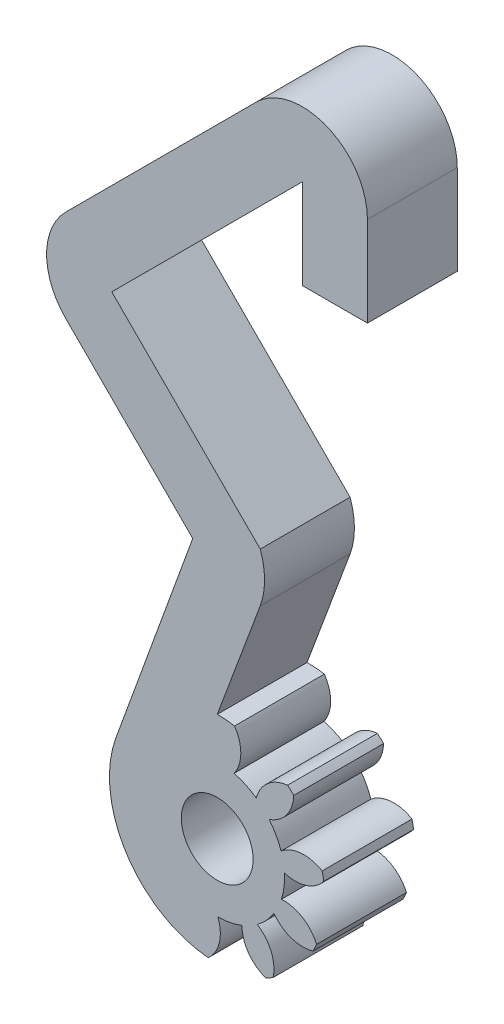
from build123d import *

# Parameters (mm, degrees)
BOSS_EXTRUDE1_DEPTH = 5
CUT_EXTRUDE1_REACH  = 47.822
SKETCH1_4_R         = 2
CUT_EXTRUDE2_DEPTH  = 5
BOSS_EXTRUDE2_DEPTH = 5
SKETCH6_R           = 2
CUT_EXTRUDE3_DEPTH  = 5


with BuildPart() as part:
    # Sketch1 → Boss-Extrude1 (new body)
    with BuildSketch(Plane.XY):
        with BuildLine():
            Line((-2.520114714, 12.269831909), (-0.124248164, 18.700029955))
            ThreePointArc((-0.124248164, 18.700029955), (0.116981353, 20.068110528), (-0.124248164, 21.436191102))
            Line((-0.124248164, 21.436191102), (-8.39066093, 29.702603869))
            Line((-8.39066093, 29.702603869), (2.215940787, 40.309205586))
            Line((2.215940787, 40.309205586), (2.215940787, 35.309205586))
            Line((2.215940787, 35.309205586), (5.841171936, 35.309205586))
            Line((5.841171936, 35.309205586), (5.841171936, 40.309205586))
            ThreePointArc((5.841171936, 40.309205586), (3.603256686, 43.658482445), (-0.347484741, 42.872631115))
            Line((-0.347484741, 42.872631115), (-10.954086459, 32.266029397))
            ThreePointArc((-10.954086459, 32.266029397), (-12.015892078, 29.702603869), (-10.954086459, 27.13917834))
            Line((-10.954086459, 27.13917834), (-3.883018647, 20.068110528))
            Line((-3.883018647, 20.068110528), (-8.158270438, 8.321952769))
            ThreePointArc((-8.158270438, 8.321952769), (0.921343905, 1.354919643), (-2.520114714, 12.269831909))
        make_face()
    extrude(amount=BOSS_EXTRUDE1_DEPTH)

    # Sketch1_4 → Cut-Extrude1 (cut, up to next)
    with BuildSketch(Plane.XY, mode=Mode.PRIVATE) as cut_extrude1_sk1:
        with Locations((-2.520114714, 6.269831909)):
            Circle(SKETCH1_4_R)
    cut_extrude1_tool1 = extrude(cut_extrude1_sk1.sketch, amount=CUT_EXTRUDE1_REACH, mode=Mode.PRIVATE) & part.part
    add(cut_extrude1_tool1.solids().sort_by_distance((-2.520115, 6.269832, 0))[0], mode=Mode.SUBTRACT)

    # Sketch5 → Cut-Extrude2 (cut)
    with BuildSketch(Plane(origin=(0, 0, 0), x_dir=(-1, 0, 0), z_dir=(0, 0, -1))):
        with BuildLine():
            Line((2.022476226, 12.24915929), (2.209173599, 10.005914968))
            ThreePointArc((2.209173599, 10.005914968), (-1.215968345, 5.958890794), (2.831055828, 2.53374885))
            Line((2.831055828, 2.53374885), (3.017753201, 0.290504527))
            ThreePointArc((3.017753201, 0.290504527), (-3.459212668, 5.772193421), (2.022476226, 12.24915929))
        make_face()
    extrude(amount=-CUT_EXTRUDE2_DEPTH, mode=Mode.SUBTRACT)

    # Sketch3 → Boss-Extrude2 (add)
    with BuildSketch(Plane.XY):
        with BuildLine():
            ThreePointArc((3.320342305, 7.644263358), (2.148599503, 7.913084677), (1.034423028, 7.461579551))
            ThreePointArc((1.034423028, 7.461579551), (0.758834569, 8.087383175), (0.37416263, 8.65272084))
            ThreePointArc((0.37416263, 8.65272084), (1.347484271, 9.358334814), (1.740439947, 10.494482662))
            ThreePointArc((1.740439947, 10.494482662), (1.571875447, 10.657954118), (1.397043733, 10.814704811))
            ThreePointArc((1.397043733, 10.814704811), (0.291074687, 10.343452688), (-0.344924962, 9.323280867))
            ThreePointArc((-0.344924962, 9.323280867), (-0.93571885, 9.667579802), (-1.579222127, 9.898843088))
            ThreePointArc((-1.579222127, 9.898843088), (-1.206537867, 11.041800891), (-1.556440997, 12.191937359))
            ThreePointArc((-1.556440997, 12.191937359), (-1.788898653, 12.225108819), (-2.022476226, 12.24915929))
            ThreePointArc((-2.022476226, 12.24915929), (-2.640228932, 11.217836019), (-2.555121505, 10.018668465))
            ThreePointArc((-2.555121505, 10.018668465), (-3.235457637, 9.949952219), (-3.891995873, 9.758806412))
            ThreePointArc((-3.891995873, 9.758806412), (-4.262301713, 10.90253701), (-5.221412546, 11.627349059))
            ThreePointArc((-5.221412546, 11.627349059), (-5.428972435, 11.517550152), (-5.632077174, 11.399713939))
            ThreePointArc((-5.632077174, 11.399713939), (-5.525653002, 10.202249956), (-4.751946644, 9.282127916))
            ThreePointArc((-4.751946644, 9.282127916), (-5.261959741, 8.826643761), (-5.680757645, 8.286100061))
            ThreePointArc((-5.680757645, 8.286100061), (-6.65260934, 8.99373724), (-7.854580137, 9.016371303))
            ThreePointArc((-7.854580137, 9.016371303), (-7.957961436, 8.805541479), (-8.053014233, 8.590828011))
            ThreePointArc((-8.053014233, 8.590828011), (-7.2630636, 7.684613857), (-6.096287842, 7.394992676))
            ThreePointArc((-6.096287842, 7.394992676), (-6.241170236, 6.726720077), (-6.262261243, 6.043247807))
            ThreePointArc((-6.262261243, 6.043247807), (-7.464444479, 6.044498216), (-8.450163248, 5.35630885))
            ThreePointArc((-8.450163248, 5.35630885), (-8.409877814, 5.124977936), (-8.360571733, 4.895400459))
            ThreePointArc((-8.360571733, 4.895400459), (-7.18882893, 4.62657914), (-6.074652455, 5.078084267))
            ThreePointArc((-6.074652455, 5.078084267), (-5.799063996, 4.452280642), (-5.414392057, 3.886942978))
            ThreePointArc((-5.414392057, 3.886942978), (-6.387713698, 3.181329004), (-6.780669374, 2.045181156))
            ThreePointArc((-6.780669374, 2.045181156), (-6.612104874, 1.881709699), (-6.43727316, 1.724959006))
            ThreePointArc((-6.43727316, 1.724959006), (-5.331304114, 2.196211129), (-4.695304465, 3.21638295))
            ThreePointArc((-4.695304465, 3.21638295), (-4.104510577, 2.872084015), (-3.4610073, 2.640820729))
            ThreePointArc((-3.4610073, 2.640820729), (-3.83369156, 1.497862927), (-3.48378843, 0.347726458))
            ThreePointArc((-3.48378843, 0.347726458), (-3.251330774, 0.314554999), (-3.017753201, 0.290504527))
            ThreePointArc((-3.017753201, 0.290504527), (-2.400000495, 1.321827799), (-2.485107922, 2.520995353))
            ThreePointArc((-2.485107922, 2.520995353), (-1.80477179, 2.589711598), (-1.148233554, 2.780857406))
            ThreePointArc((-1.148233554, 2.780857406), (-0.777927714, 1.637126807), (0.181183119, 0.912314758))
            ThreePointArc((0.181183119, 0.912314758), (0.388743008, 1.022113666), (0.591847747, 1.139949878))
            ThreePointArc((0.591847747, 1.139949878), (0.485423575, 2.337413862), (-0.288282783, 3.257535901))
            ThreePointArc((-0.288282783, 3.257535901), (0.221730314, 3.713020057), (0.640528217, 4.253563756))
            ThreePointArc((0.640528217, 4.253563756), (1.612379913, 3.545926577), (2.81435071, 3.523292514))
            ThreePointArc((2.81435071, 3.523292514), (2.917732009, 3.734122338), (3.012784806, 3.948835807))
            ThreePointArc((3.012784806, 3.948835807), (2.222834173, 4.855049961), (1.056058415, 5.144671141))
            ThreePointArc((1.056058415, 5.144671141), (1.200940809, 5.81294374), (1.222031815, 6.496416011))
            ThreePointArc((1.222031815, 6.496416011), (2.424215051, 6.495165601), (3.409933821, 7.183354967))
            ThreePointArc((3.409933821, 7.183354967), (3.369648387, 7.414685881), (3.320342305, 7.644263358))
        make_face()
    extrude(amount=BOSS_EXTRUDE2_DEPTH)

    # Sketch6 → Cut-Extrude3 (cut)
    with BuildSketch(Plane(origin=(0, 0, 0), x_dir=(-1, 0, 0), z_dir=(0, 0, -1))):
        with Locations((2.520114714, 6.269831909)):
            Circle(SKETCH6_R)
    extrude(amount=-CUT_EXTRUDE3_DEPTH, mode=Mode.SUBTRACT)


solid = part.part
